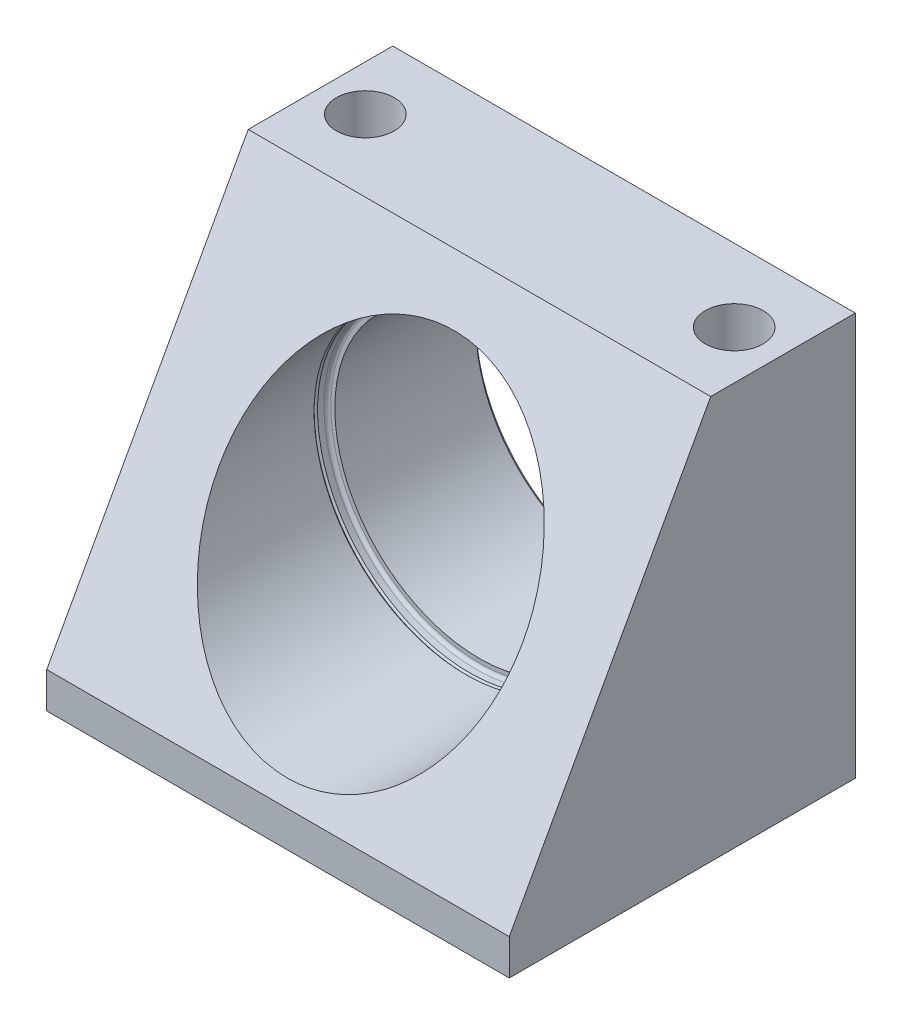
from build123d import *

# Parameters (mm, degrees)
SKETCH1_W          = 101.6
SKETCH1_H          = 88.4936
SKETCH1_R          = 31.7627
EXTRUDE1_DEPTH     = 75.9968
CUT_EXTRUDE1_DEPTH = 102.6
SKETCH3_R          = 33.401
CUT_EXTRUDE2_DEPTH = 44.2468
FILLET1_R          = 0.762
HOLE1_D            = 12.7
HOLE1_DEPTH        = 88.4936


with BuildPart() as part:
    # Sketch1 → Extrude1 (new body)
    with BuildSketch(Plane.XY):
        with Locations((50.8, 44.2468)):
            Rectangle(SKETCH1_W, SKETCH1_H)
        with Locations((50.8, 45.0088)):
            Circle(SKETCH1_R, mode=Mode.SUBTRACT)
    extrude(amount=-EXTRUDE1_DEPTH)

    # Sketch2 → Cut-Extrude1 (cut, through all)
    with BuildSketch(Plane(origin=(101.6, 0, 0), x_dir=(0, 0, -1), z_dir=(1, 0, 0))):
        Polygon((0, 88.4936), (44.2468, 88.4936), (0, 7.874), align=None)
    extrude(amount=-CUT_EXTRUDE1_DEPTH, mode=Mode.SUBTRACT)

    # Sketch3 → Cut-Extrude2 (cut)
    with BuildSketch(Plane(origin=(0, 0, 0), x_dir=(-1, 0, 0), z_dir=(0, 0, -1))):
        with Locations(Location((-50.8, 45.0088, 0), (0, 0, 180))):  # turned: the seam where the file's is
            Circle(SKETCH3_R)
    extrude(amount=CUT_EXTRUDE2_DEPTH, mode=Mode.SUBTRACT)

    # Fillet1
    fillet1_edges = [part.edges().sort_by_distance(p)[0] for p in [
        (17.399, 45.0088, -44.2468),
    ]]
    fillet(fillet1_edges, radius=FILLET1_R)

    # Hole1
    with Locations(Plane(origin=(0, 88.4936, 0), x_dir=(-1, 0, 0), z_dir=(0, 1, 0))):
        with Locations((-9.9822, -59.9948), (-91.0082, -59.9948)):
            Hole(HOLE1_D / 2, depth=HOLE1_DEPTH)

    # Sketch6 → Cut-Revolve1 (revolve, cut)
    with BuildSketch(Plane(origin=(0, 45.0088, 0), x_dir=(-1, 0, 0), z_dir=(0, 1, 0)), mode=Mode.PRIVATE) as cut_revolve1_sk:
        Polygon((-17.399, -41.3258), (-17.399, -42.0878), (-17.018, -41.7068), align=None)
        Polygon((-19.0373, -75.2475), (-19.0373, -75.9968), (-18.288, -75.9968), align=None)
    revolve(cut_revolve1_sk.sketch.rotate(Axis((50.8, 45.0088, 17.508123997), (0, 0, -1)), 180), axis=Axis((50.8, 45.0088, 17.508123997), (0, 0, -1)), mode=Mode.SUBTRACT)  # turned: the seam where the file's is


solid = part.part
